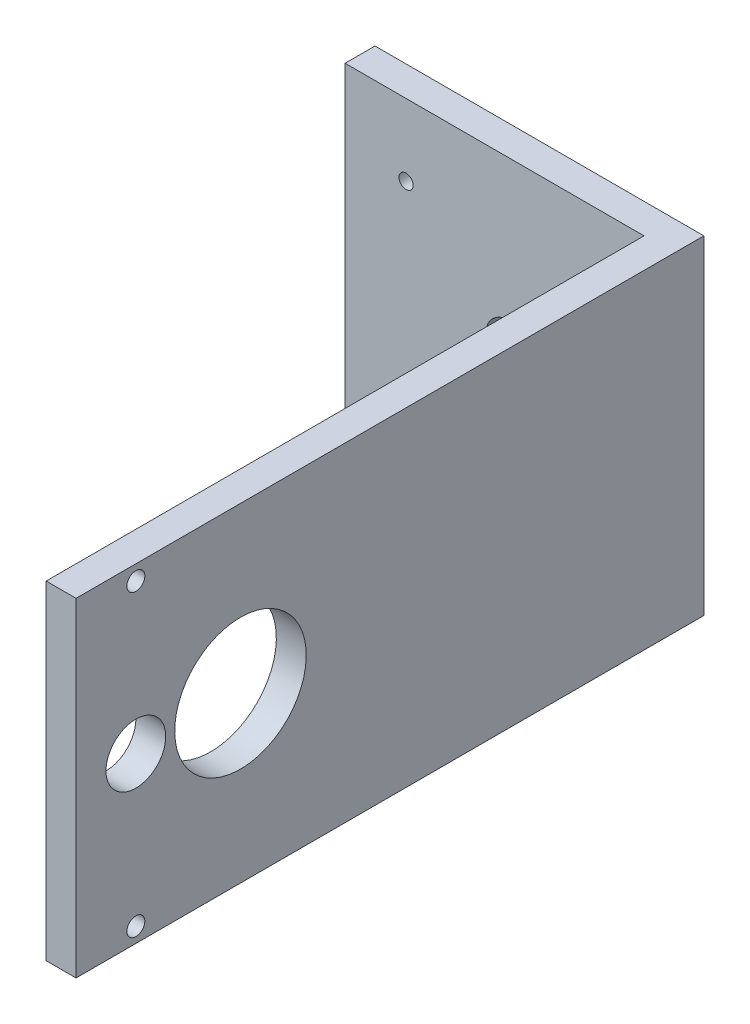
from build123d import *

# Parameters (mm, degrees)
SKETCH1_W                 = 55
SKETCH1_H                 = 55
BOSS_EXTRUDE1_DEPTH       = 5
SKETCH2_W                 = 5
SKETCH2_H                 = 55
BOSS_EXTRUDE2_DEPTH       = 100
CUT_EXTRUDE1_REACH        = 57
SKETCH3_R                 = 5
SKETCH3_R_2               = 1.5
SKETCH3_R_3               = 11
CUT_EXTRUDE2_REACH        = 7
SKETCH4_R                 = 4
F_4_48_TAPPED_HOLE1_D     = 2.3749
F_4_48_TAPPED_HOLE1_DEPTH = 3.5
F_4_48_TAPPED_HOLE1_TIP   = 0.713491942


with BuildPart() as part:
    # Sketch1 → Boss-Extrude1 (new body)
    with BuildSketch(Plane.XY):
        Rectangle(SKETCH1_W, SKETCH1_H)
    extrude(amount=BOSS_EXTRUDE1_DEPTH)

    # Sketch2 → Boss-Extrude2 (add)
    with BuildSketch(Plane.XY.offset(5)):
        with Locations((25, 0)):
            Rectangle(SKETCH2_W, SKETCH2_H)
    extrude(amount=BOSS_EXTRUDE2_DEPTH)

    # Sketch3 → Cut-Extrude1 (cut, up to next)
    with BuildSketch(Plane(origin=(27.5, 0, 0), x_dir=(0, 0, -1), z_dir=(1, 0, 0)), mode=Mode.PRIVATE) as cut_extrude1_sk1:
        with Locations((-95, 0)):
            Circle(SKETCH3_R)
    cut_extrude1_tool1 = extrude(cut_extrude1_sk1.sketch, amount=-CUT_EXTRUDE1_REACH, mode=Mode.PRIVATE) & part.part
    add(cut_extrude1_tool1.solids().sort_by_distance((27.5, 0, 95))[0], mode=Mode.SUBTRACT)
    # Sketch3 → Cut-Extrude1 (cut, up to next)
    with BuildSketch(Plane(origin=(27.5, 0, 0), x_dir=(0, 0, -1), z_dir=(1, 0, 0)), mode=Mode.PRIVATE) as cut_extrude1_sk2:
        with Locations((-95, 25)):
            Circle(SKETCH3_R_2)
    cut_extrude1_tool2 = extrude(cut_extrude1_sk2.sketch, amount=-CUT_EXTRUDE1_REACH, mode=Mode.PRIVATE) & part.part
    add(cut_extrude1_tool2.solids().sort_by_distance((27.5, 25, 95))[0], mode=Mode.SUBTRACT)
    # Sketch3 → Cut-Extrude1 (cut, up to next)
    with BuildSketch(Plane(origin=(27.5, 0, 0), x_dir=(0, 0, -1), z_dir=(1, 0, 0)), mode=Mode.PRIVATE) as cut_extrude1_sk3:
        with Locations((-95, -25)):
            Circle(SKETCH3_R_2)
    cut_extrude1_tool3 = extrude(cut_extrude1_sk3.sketch, amount=-CUT_EXTRUDE1_REACH, mode=Mode.PRIVATE) & part.part
    add(cut_extrude1_tool3.solids().sort_by_distance((27.5, -25, 95))[0], mode=Mode.SUBTRACT)
    # Sketch3 → Cut-Extrude1 (cut, up to next)
    with BuildSketch(Plane(origin=(27.5, 0, 0), x_dir=(0, 0, -1), z_dir=(1, 0, 0)), mode=Mode.PRIVATE) as cut_extrude1_sk4:
        with Locations((-77.5, 0)):
            Circle(SKETCH3_R_3)
    cut_extrude1_tool4 = extrude(cut_extrude1_sk4.sketch, amount=-CUT_EXTRUDE1_REACH, mode=Mode.PRIVATE) & part.part
    add(cut_extrude1_tool4.solids().sort_by_distance((27.5, 0, 77.5))[0], mode=Mode.SUBTRACT)

    # Sketch4 → Cut-Extrude2 (cut, up to next)
    with BuildSketch(Plane.XY.offset(5), mode=Mode.PRIVATE) as cut_extrude2_sk1:
        Circle(SKETCH4_R)
    cut_extrude2_tool1 = extrude(cut_extrude2_sk1.sketch, amount=-CUT_EXTRUDE2_REACH, mode=Mode.PRIVATE) & part.part
    add(cut_extrude2_tool1.solids().sort_by_distance((0, 0, 5))[0], mode=Mode.SUBTRACT)

    # #4-48 Tapped Hole1
    with Locations(Plane.XY.offset(5)):
        with Locations((-17.3, 15.5), (-17.3, -15.5)):
            Hole(F_4_48_TAPPED_HOLE1_D / 2, depth=F_4_48_TAPPED_HOLE1_DEPTH)
            with Locations((0, 0, -(F_4_48_TAPPED_HOLE1_DEPTH + F_4_48_TAPPED_HOLE1_TIP / 2))):  # 118° drill point
                Cone(0, F_4_48_TAPPED_HOLE1_D / 2, F_4_48_TAPPED_HOLE1_TIP, mode=Mode.SUBTRACT)


solid = part.part
